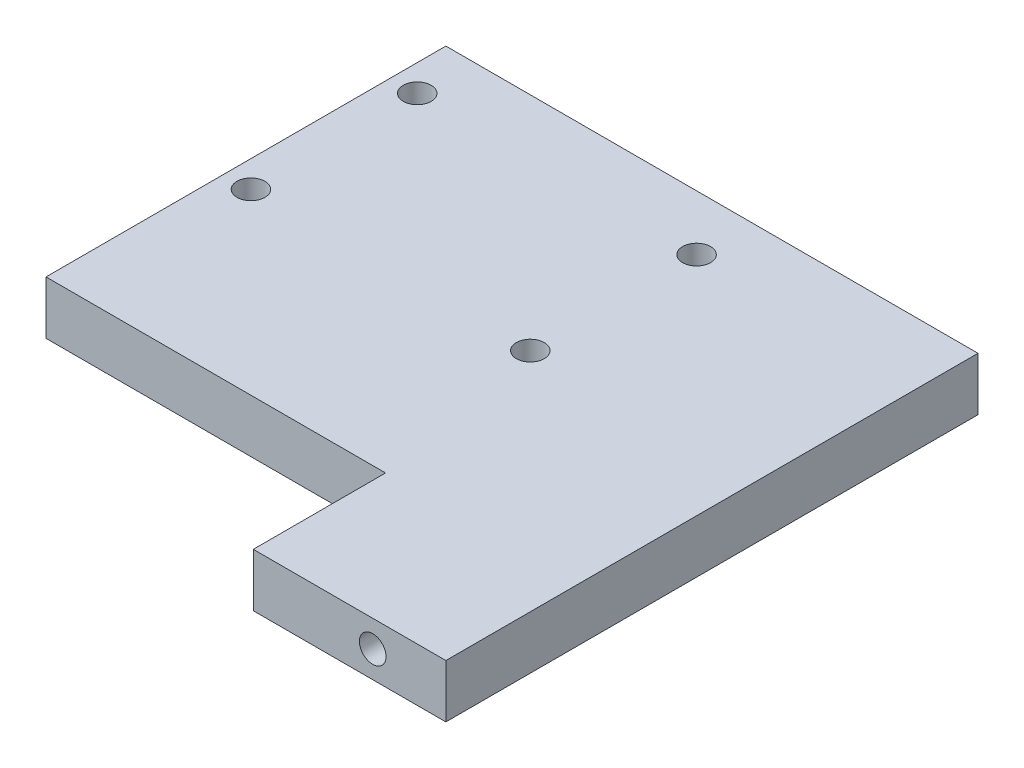
from build123d import *

# Parameters (mm, degrees)
SKETCH1_W           = 40
SKETCH1_H           = 40
BOSS_EXTRUDE1_DEPTH = 4
SKETCH4_R           = 1
CUT_EXTRUDE2_DEPTH  = 2
SKETCH5_R           = 1
CUT_EXTRUDE3_DEPTH  = 2
SKETCH6_W           = 25
SKETCH6_H           = 17.723883745
SKETCH6_R           = 1.05
BOSS_EXTRUDE3_DEPTH = 1
SKETCH8_R           = 1.05
CUT_EXTRUDE4_DEPTH  = 29.722813233
SKETCH9_W           = 25.523793116
SKETCH9_H           = 9.941729438
CUT_EXTRUDE5_DEPTH  = 29.565713714


with BuildPart() as part:
    # Sketch1 → Boss-Extrude1 (new body)
    with BuildSketch(Plane(origin=(0, 0, 0), x_dir=(1, 0, 0), z_dir=(0, 1, 0))):
        Rectangle(SKETCH1_W, SKETCH1_H)
    extrude(amount=BOSS_EXTRUDE1_DEPTH)

    # Sketch4 → Cut-Extrude2 (cut)
    with BuildSketch(Plane.XY.offset(20)):
        with Locations((-14.5, 2)):
            Circle(SKETCH4_R)
        with Locations((14.5, 2)):
            Circle(SKETCH4_R)
    extrude(amount=-CUT_EXTRUDE2_DEPTH, mode=Mode.SUBTRACT)

    # Sketch5 → Cut-Extrude3 (cut)
    with BuildSketch(Plane(origin=(0, 0, -20), x_dir=(-1, 0, 0), z_dir=(0, 0, -1))):
        with Locations(Location((-14.5, 2, 0), (0, 0, 180))):
            Circle(SKETCH5_R)
        with Locations(Location((14.5, 2, 0), (0, 0, 180))):
            Circle(SKETCH5_R)
    extrude(amount=-CUT_EXTRUDE3_DEPTH, mode=Mode.SUBTRACT)

    # Sketch6 → Boss-Extrude3 (add)
    with BuildSketch(Plane(origin=(0, 0, 0), x_dir=(-1, 0, 0), z_dir=(0, -1, 0))):
        with Locations((7.5, 8.985238628)):
            Rectangle(SKETCH6_W, SKETCH6_H)
        with Locations(Location((17.998887809, 15.84606831, 0), (0, 0, 90))):
            Circle(SKETCH6_R, mode=Mode.SUBTRACT)
        with Locations(Location((-2.998887809, 15.84606831, 0), (0, 0, 90))):
            Circle(SKETCH6_R, mode=Mode.SUBTRACT)
        with Locations(Location((-2.998887809, 3.34606831, 0), (0, 0, 90))):
            Circle(SKETCH6_R, mode=Mode.SUBTRACT)
        with Locations(Location((17.998887809, 3.34606831, 0), (0, 0, 90))):
            Circle(SKETCH6_R, mode=Mode.SUBTRACT)
    extrude(amount=BOSS_EXTRUDE3_DEPTH)

    # Sketch8 → Cut-Extrude4 (cut, through all)
    with BuildSketch(Plane.XZ.offset(1)):
        with Locations(Location((-17.998887809, -15.84606831, 0), (0, 0, 270))):
            Circle(SKETCH8_R)
        with Locations(Location((2.998887809, -15.84606831, 0), (0, 0, 270))):
            Circle(SKETCH8_R)
        with Locations(Location((2.998887809, -3.34606831, 0), (0, 0, 270))):
            Circle(SKETCH8_R)
        with Locations(Location((-17.998887809, -3.34606831, 0), (0, 0, 270))):
            Circle(SKETCH8_R)
    extrude(amount=-CUT_EXTRUDE4_DEPTH, mode=Mode.SUBTRACT)

    # Sketch9 → Cut-Extrude5 (cut, through all)
    with BuildSketch(Plane(origin=(0, 0, 0), x_dir=(-1, 0, 0), z_dir=(0, -1, 0))):
        with Locations((7.238103442, -15.029135281)):
            Rectangle(SKETCH9_W, SKETCH9_H)
    extrude(amount=-CUT_EXTRUDE5_DEPTH, mode=Mode.SUBTRACT)


solid = part.part
